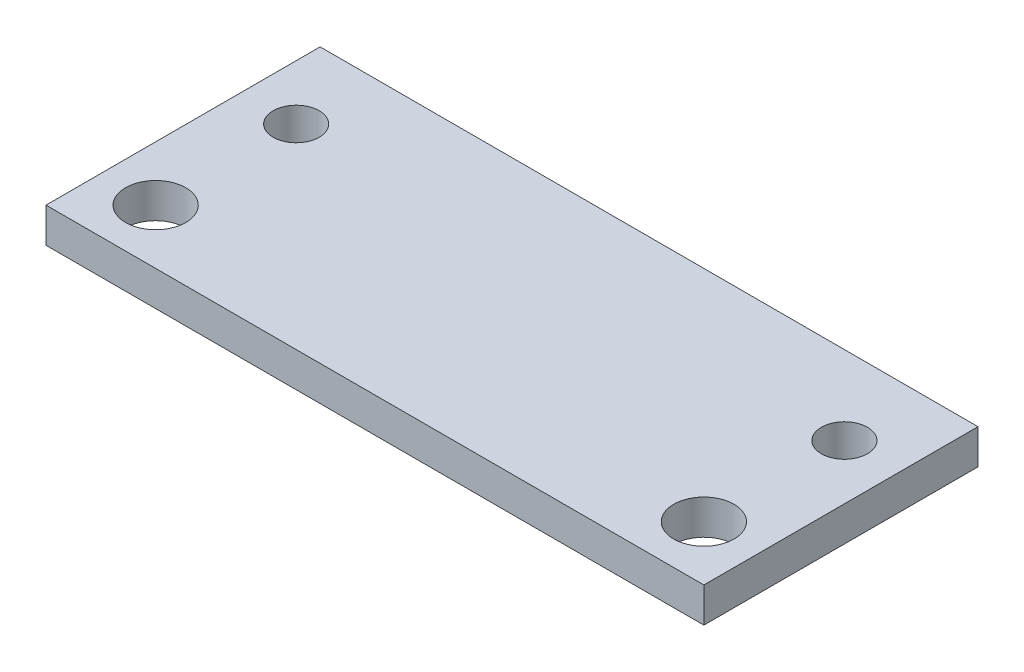
from build123d import *

# Parameters (mm, degrees)
SKETCH1_W                 = 60
SKETCH1_H                 = 25
BOSS_EXTRUDE1_DEPTH       = 3.175
M5_CLEARANCE_HOLE2_D      = 5.5
M5_CLEARANCE_HOLE2_DEPTH  = 15
M5_CLEARANCE_HOLE2_TIP    = 1.652366702
M5X0_8_TAPPED_HOLE2_D     = 4.2
M5X0_8_TAPPED_HOLE2_DEPTH = 15
M5X0_8_TAPPED_HOLE2_TIP   = 1.2618073


with BuildPart() as part:
    # Sketch1 → Boss-Extrude1 (new body)
    with BuildSketch(Plane(origin=(0, 0, 0), x_dir=(1, 0, 0), z_dir=(0, 1, 0))):
        with Locations((-30, 12.5)):
            Rectangle(SKETCH1_W, SKETCH1_H)
    extrude(amount=BOSS_EXTRUDE1_DEPTH)

    # M5 Clearance Hole2
    with Locations(Plane(origin=(-55, 3.175, -5), x_dir=(0, 0, 1), z_dir=(0, 1, 0))):
        with Locations((0, 0), (0, 50)):
            Hole(M5_CLEARANCE_HOLE2_D / 2, depth=M5_CLEARANCE_HOLE2_DEPTH)
            with Locations((0, 0, -(M5_CLEARANCE_HOLE2_DEPTH + M5_CLEARANCE_HOLE2_TIP / 2))):  # 118° drill point
                Cone(0, M5_CLEARANCE_HOLE2_D / 2, M5_CLEARANCE_HOLE2_TIP, mode=Mode.SUBTRACT)

    # M5x0.8 Tapped Hole2
    with Locations(Plane(origin=(-55, 3.175, -17.8156), x_dir=(0, 0, 1), z_dir=(0, 1, 0))):
        with Locations((0, 0), (0, 50)):
            Hole(M5X0_8_TAPPED_HOLE2_D / 2, depth=M5X0_8_TAPPED_HOLE2_DEPTH)
            with Locations((0, 0, -(M5X0_8_TAPPED_HOLE2_DEPTH + M5X0_8_TAPPED_HOLE2_TIP / 2))):  # 118° drill point
                Cone(0, M5X0_8_TAPPED_HOLE2_D / 2, M5X0_8_TAPPED_HOLE2_TIP, mode=Mode.SUBTRACT)


solid = part.part
